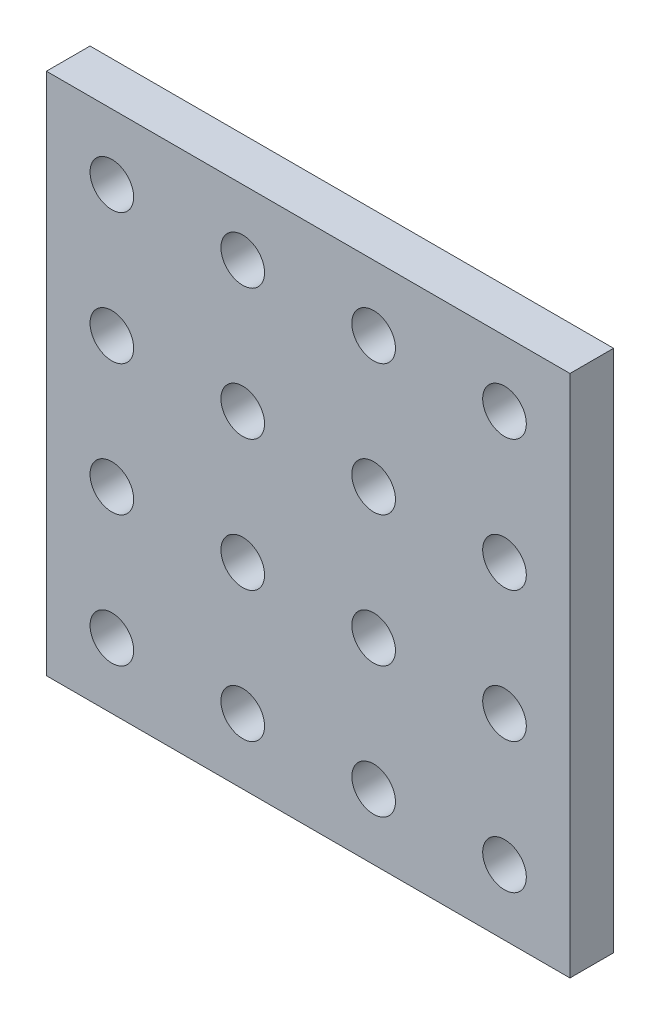
from build123d import *

# Parameters (mm, degrees)
SKETCH1_W           = 120
SKETCH1_H           = 120
SKETCH1_R           = 5
BOSS_EXTRUDE1_DEPTH = 10


with BuildPart() as part:
    # Sketch1 → Boss-Extrude1 (new body)
    with BuildSketch(Plane.XY):
        with Locations((60, 60)):
            Rectangle(SKETCH1_W, SKETCH1_H)
        with Locations((15, 105)):
            Circle(SKETCH1_R, mode=Mode.SUBTRACT)
        with Locations((45, 105)):
            Circle(SKETCH1_R, mode=Mode.SUBTRACT)
        with Locations((75, 105)):
            Circle(SKETCH1_R, mode=Mode.SUBTRACT)
        with Locations((105, 105)):
            Circle(SKETCH1_R, mode=Mode.SUBTRACT)
        with Locations((45, 75)):
            Circle(SKETCH1_R, mode=Mode.SUBTRACT)
        with Locations((75, 75)):
            Circle(SKETCH1_R, mode=Mode.SUBTRACT)
        with Locations((105, 75)):
            Circle(SKETCH1_R, mode=Mode.SUBTRACT)
        with Locations((45, 45)):
            Circle(SKETCH1_R, mode=Mode.SUBTRACT)
        with Locations((75, 45)):
            Circle(SKETCH1_R, mode=Mode.SUBTRACT)
        with Locations((105, 45)):
            Circle(SKETCH1_R, mode=Mode.SUBTRACT)
        with Locations((45, 15)):
            Circle(SKETCH1_R, mode=Mode.SUBTRACT)
        with Locations((75, 15)):
            Circle(SKETCH1_R, mode=Mode.SUBTRACT)
        with Locations((105, 15)):
            Circle(SKETCH1_R, mode=Mode.SUBTRACT)
        with Locations((15, 75)):
            Circle(SKETCH1_R, mode=Mode.SUBTRACT)
        with Locations((15, 45)):
            Circle(SKETCH1_R, mode=Mode.SUBTRACT)
        with Locations((15, 15)):
            Circle(SKETCH1_R, mode=Mode.SUBTRACT)
    extrude(amount=BOSS_EXTRUDE1_DEPTH)


solid = part.part
